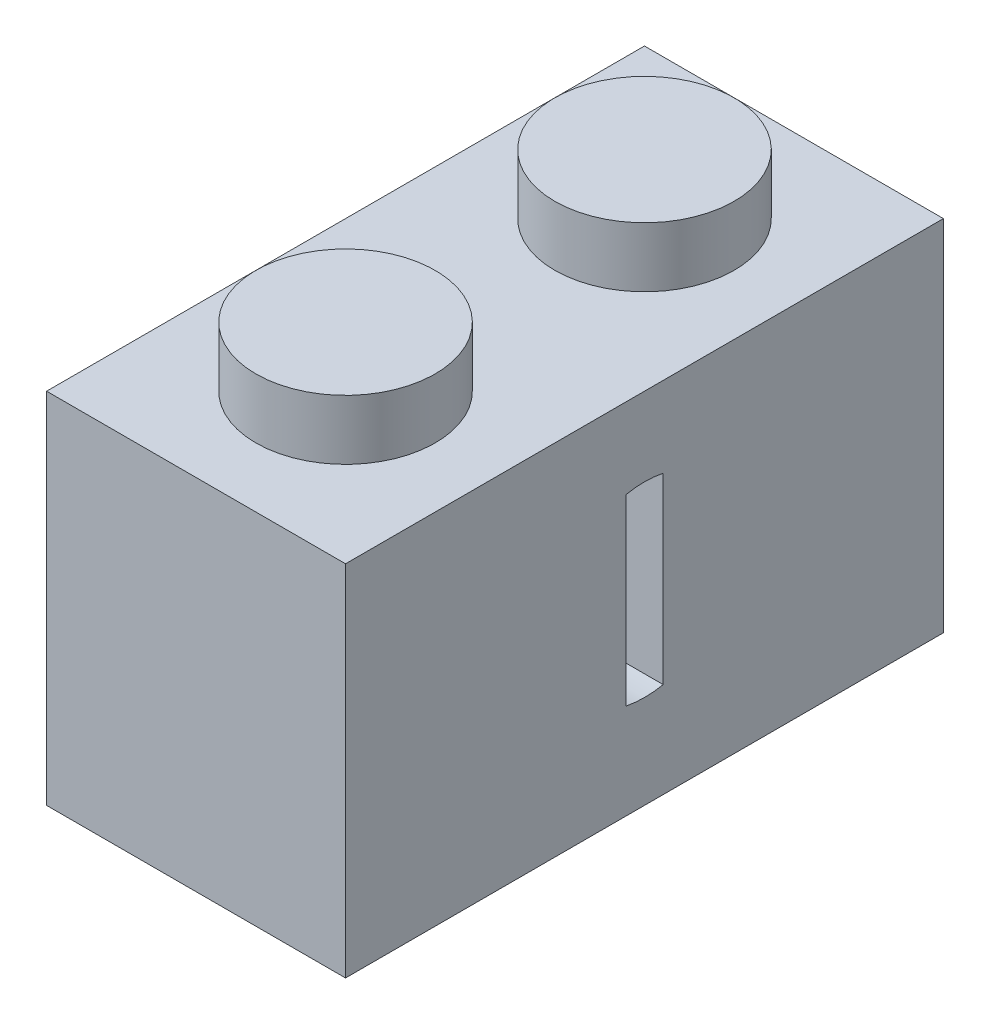
from build123d import *

# Parameters (mm, degrees)
SKETCH1_W           = 8
SKETCH1_H           = 9.6
BOSS_EXTRUDE1_DEPTH = 16
SKETCH4_W           = 4.8
SKETCH4_H           = 12.8
CUT_EXTRUDE1_DEPTH  = 8
SKETCH5_R           = 2.4
BOSS_EXTRUDE2_DEPTH = 1.6
BOSS_EXTRUDE3_DEPTH = 4.8
SKETCH7_R           = 2.5
CUT_EXTRUDE2_DEPTH  = 3.5
CUT_EXTRUDE3_DEPTH  = 4.5
SKETCH9_R           = 3.25
SKETCH9_R_2         = 2.5
BOSS_EXTRUDE4_DEPTH = 1.6
SKETCH10_W          = 1.6
SKETCH10_H          = 6.5
CUT_EXTRUDE4_DEPTH  = 1


with BuildPart() as part:
    # Sketch1 → Boss-Extrude1 (new body)
    with BuildSketch(Plane.XY):
        with Locations((4, 4.8)):
            Rectangle(SKETCH1_W, SKETCH1_H)
    extrude(amount=BOSS_EXTRUDE1_DEPTH)

    # Sketch4 → Cut-Extrude1 (cut)
    with BuildSketch(Plane.XZ):
        with Locations((4, 8)):
            Rectangle(SKETCH4_W, SKETCH4_H)
    extrude(amount=-CUT_EXTRUDE1_DEPTH, mode=Mode.SUBTRACT)

    # Sketch5 → Boss-Extrude2 (add)
    with BuildSketch(Plane(origin=(0, 9.6, 0), x_dir=(1, 0, 0), z_dir=(0, 1, 0))):
        with Locations((4, -12)):
            Circle(SKETCH5_R)
        with Locations((4, -4)):
            Circle(SKETCH5_R)
    extrude(amount=BOSS_EXTRUDE2_DEPTH)

    # Sketch6 → Boss-Extrude3 (add)
    with BuildSketch(Plane.ZY.offset(-6.4)):
        with BuildLine():
            ThreePointArc((9.802775638, 8), (8, 8.5), (6.197224362, 8))
            Line((6.197224362, 8), (9.802775638, 8))
        make_face()
        with BuildLine():
            Line((9.802775638, 8), (6.197224362, 8))
            ThreePointArc((6.197224362, 8), (6.276589824, 1.953714169), (11.5, 5))
            ThreePointArc((11.5, 5), (11.046285831, 6.723410176), (9.802775638, 8))
        make_face()
    extrude(amount=BOSS_EXTRUDE3_DEPTH)

    # Sketch7 → Cut-Extrude2 (cut)
    with BuildSketch(Plane.ZY):
        with Locations((8, 5)):
            Circle(SKETCH7_R)
    extrude(amount=-CUT_EXTRUDE2_DEPTH, mode=Mode.SUBTRACT)

    # Sketch8 → Cut-Extrude3 (cut)
    with BuildSketch(Plane.ZY.offset(-3.5)):
        with BuildLine():
            ThreePointArc((8.5, 7.449489743), (8, 7.5), (7.5, 7.449489743))
            Line((7.5, 7.449489743), (7.5, 2.550510257))
            ThreePointArc((7.5, 2.550510257), (8, 2.5), (8.5, 2.550510257))
            Line((8.5, 2.550510257), (8.5, 7.449489743))
        make_face()
    extrude(amount=-CUT_EXTRUDE3_DEPTH, mode=Mode.SUBTRACT)

    # Sketch9 → Boss-Extrude4 (add)
    with BuildSketch(Plane.ZY):
        with Locations((8, 5)):
            Circle(SKETCH9_R)
        with Locations((8, 5)):
            Circle(SKETCH9_R_2, mode=Mode.SUBTRACT)
    extrude(amount=BOSS_EXTRUDE4_DEPTH)

    # Sketch10 → Cut-Extrude4 (cut)
    with BuildSketch(Plane(origin=(0, 8.25, 0), x_dir=(1, 0, 0), z_dir=(0, 1, 0))):
        with Locations((-0.8, -8)):
            Rectangle(SKETCH10_W, SKETCH10_H)
    extrude(amount=-CUT_EXTRUDE4_DEPTH, mode=Mode.SUBTRACT)


solid = part.part
